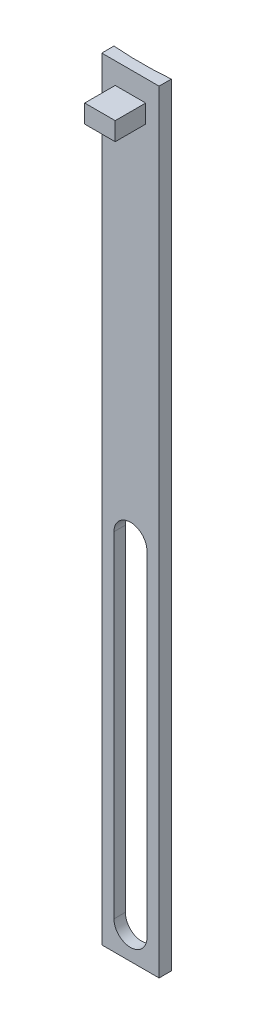
from build123d import *

# Parameters (mm, degrees)
SKETCH1_W               = 9.4
SKETCH1_H               = 126.7
BOSS_EXTRUDE1_DEPTH     = 1
CUT_EXTRUDE2_DEPTH      = 35.5
CUT_EXTRUDE2_DEPTH_BACK = 93.2
SKETCH3_W               = 5
SKETCH3_H               = 3
BOSS_EXTRUDE2_DEPTH     = 5


with BuildPart() as part:
    # Sketch1 → Boss-Extrude1 (new body, symmetric)
    with BuildSketch(Plane.XY):
        with Locations((0, -28.85)):
            Rectangle(SKETCH1_W, SKETCH1_H)
        with BuildLine():
            ThreePointArc((-2.7, -32.5), (0, -29.8), (2.7, -32.5))
            Line((2.7, -32.5), (2.7, -87.5))
            ThreePointArc((2.7, -87.5), (0, -90.2), (-2.7, -87.5))
            Line((-2.7, -87.5), (-2.7, -32.5))
        make_face(mode=Mode.SUBTRACT)
    extrude(amount=BOSS_EXTRUDE1_DEPTH, both=True)

    # Sketch2 → Cut-Extrude2 (cut, two sides)
    with BuildSketch(Plane(origin=(0, 0, 0), x_dir=(1, 0, 0), z_dir=(0, 1, 0))) as cut_extrude2_sk:
        with BuildLine():
            ThreePointArc((-4.7, 1), (0, 0.805897581), (4.7, 1))
            Line((4.7, 1), (-4.7, 1))
        make_face()
        with BuildLine():
            Line((-4.7, 1), (4.7, 1))
            ThreePointArc((4.7, 1), (41.93387652, 19.198255851), (57, 57.805897581))
            ThreePointArc((57, 57.805897581), (-38.607641731, 99.739774101), (-4.7, 1))
        make_face()
    extrude(amount=CUT_EXTRUDE2_DEPTH, mode=Mode.SUBTRACT)
    extrude(cut_extrude2_sk.sketch, amount=-CUT_EXTRUDE2_DEPTH_BACK, mode=Mode.SUBTRACT)

    # Sketch3 → Boss-Extrude2 (add)
    with BuildSketch(Plane.XY.offset(1)):
        with Locations((0, 29.5)):
            Rectangle(SKETCH3_W, SKETCH3_H)
    extrude(amount=BOSS_EXTRUDE2_DEPTH)


solid = part.part
